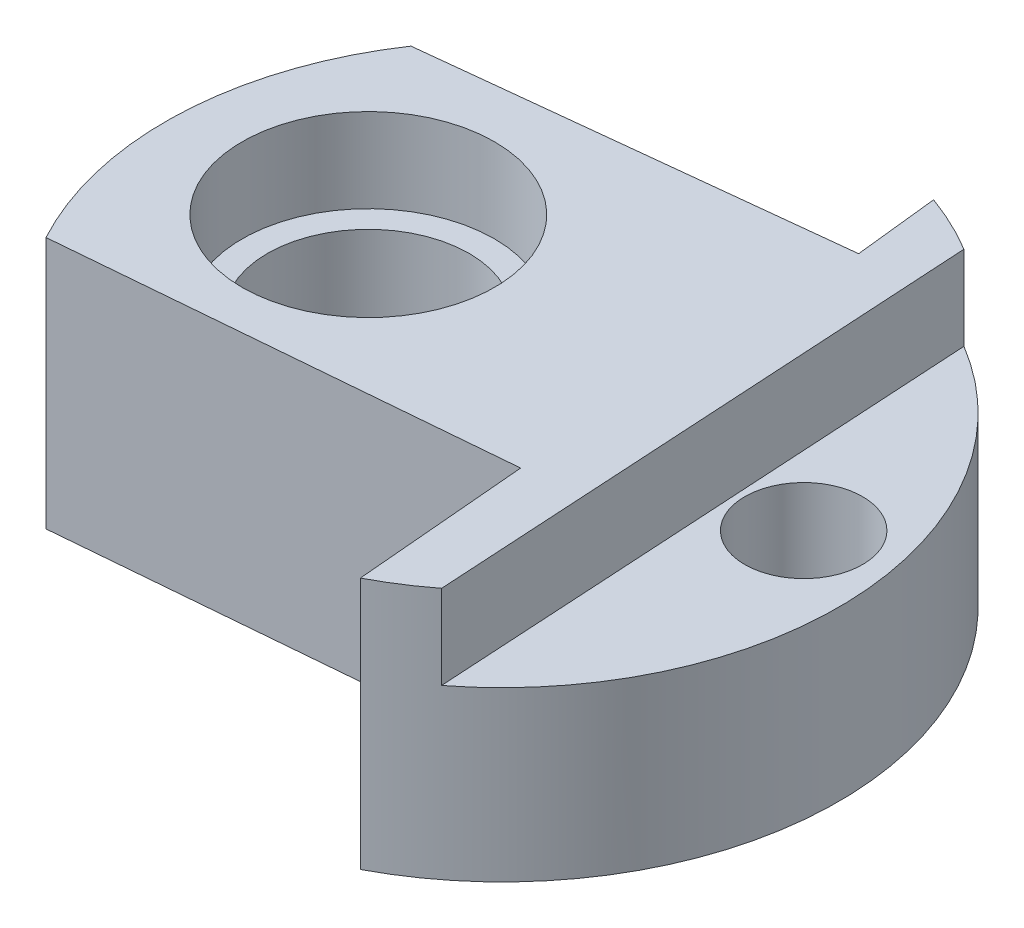
from build123d import *

# Parameters (mm, degrees)
SKETCH1_R               = 20
BOSS_EXTRUDE1_DEPTH     = 15
CUT_EXTRUDE1_DEPTH      = 1
CUT_EXTRUDE1_DEPTH_BACK = 5
SKETCH3_R               = 3.5
CUT_EXTRUDE2_DEPTH      = 11
SKETCH5_R               = 7.5
CUT_EXTRUDE4_DEPTH      = 5
SKETCH4_R               = 6
CUT_EXTRUDE5_DEPTH      = 16
CUT_EXTRUDE6_DEPTH      = 1
CUT_EXTRUDE6_DEPTH_BACK = 16
CUT_EXTRUDE7_DEPTH      = 1
CUT_EXTRUDE7_DEPTH_BACK = 16


with BuildPart() as part:
    # Sketch1 → Boss-Extrude1 (new body)
    with BuildSketch(Plane(origin=(0, 0, 0), x_dir=(1, 0, 0), z_dir=(0, 1, 0))):
        Circle(SKETCH1_R)
    extrude(amount=BOSS_EXTRUDE1_DEPTH)

    # Sketch2 → Cut-Extrude1 (cut, two sides)
    with BuildSketch(Plane(origin=(0, 15, 0), x_dir=(1, 0, 0), z_dir=(0, 1, 0))) as cut_extrude1_sk:
        Polygon((4.074284854, 123.342943671), (10.2938366, 17.14750501), (12.225151258, -15.828634708), (18.444703004, -122.024073369), (230.835580327, -109.584969878), (216.465162177, 135.782047162), align=None)
    extrude(amount=CUT_EXTRUDE1_DEPTH, mode=Mode.SUBTRACT)
    extrude(cut_extrude1_sk.sketch, amount=-CUT_EXTRUDE1_DEPTH_BACK, mode=Mode.SUBTRACT)

    # Sketch3 → Cut-Extrude2 (cut, through all)
    with BuildSketch(Plane(origin=(0, 10, 0), x_dir=(1, 0, 0), z_dir=(0, 1, 0))):
        with Locations((15.014261177, 2.902690148)):
            Circle(SKETCH3_R)
    extrude(amount=-CUT_EXTRUDE2_DEPTH, mode=Mode.SUBTRACT)

    # Sketch5 → Cut-Extrude4 (cut)
    with BuildSketch(Plane(origin=(0, 15, 0), x_dir=(1, 0, 0), z_dir=(0, 1, 0))):
        with Locations((-9.188292451, 1.230126279)):
            Circle(SKETCH5_R)
    extrude(amount=-CUT_EXTRUDE4_DEPTH, mode=Mode.SUBTRACT)

    # Sketch4 → Cut-Extrude5 (cut, through all)
    with BuildSketch(Plane(origin=(0, 15, 0), x_dir=(1, 0, 0), z_dir=(0, 1, 0))):
        with Locations((-9.188292451, 1.230126279)):
            Circle(SKETCH4_R)
    extrude(amount=-CUT_EXTRUDE5_DEPTH, mode=Mode.SUBTRACT)

    # Sketch6 → Cut-Extrude6 (cut, two sides)
    with BuildSketch(Plane(origin=(0, 15, 0), x_dir=(1, 0, 0), z_dir=(0, 1, 0))) as cut_extrude6_sk:
        Polygon((-122.787131769, -18.599673993), (-17.584679199, -9.527804442), (8.38493326, -7.288380068), (9.284012328, -17.714601748), (18.355881879, -122.917054318), (-107.166589312, -292.750880754), (-248.30960296, -188.433500429), align=None)
    extrude(amount=CUT_EXTRUDE6_DEPTH, mode=Mode.SUBTRACT)
    extrude(cut_extrude6_sk.sketch, amount=-CUT_EXTRUDE6_DEPTH_BACK, mode=Mode.SUBTRACT)

    # Sketch7 → Cut-Extrude7 (cut, two sides)
    with BuildSketch(Plane(origin=(0, 15, 0), x_dir=(1, 0, 0), z_dir=(0, 1, 0))) as cut_extrude7_sk:
        Polygon((-119.21548429, -0.03712377), (-16.591552302, 11.167828446), (7.395972386, 13.786896559), (6.849658032, 18.79048123), (-4.355294184, 121.414413217), (-154.363796188, 263.281741412), (-269.223986293, 141.830204426), align=None)
    extrude(amount=CUT_EXTRUDE7_DEPTH, mode=Mode.SUBTRACT)
    extrude(cut_extrude7_sk.sketch, amount=-CUT_EXTRUDE7_DEPTH_BACK, mode=Mode.SUBTRACT)


solid = part.part
